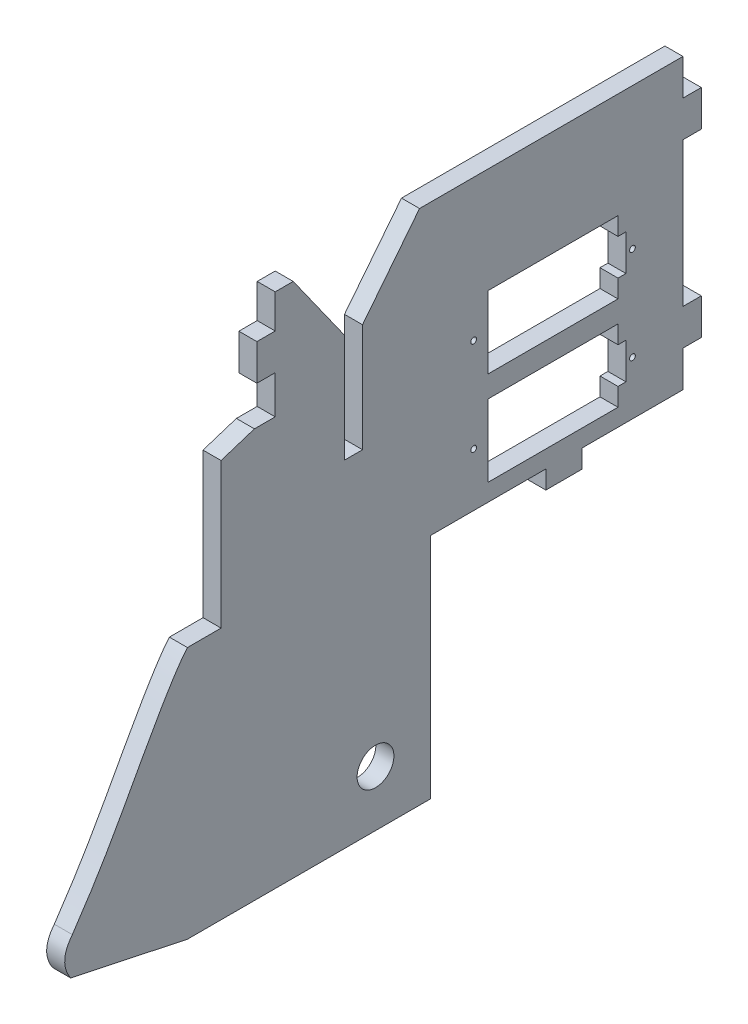
from build123d import *

# Parameters (mm, degrees)
SKETCH1_W                = 71.755
SKETCH1_H                = 50.8
MAIN_BODY_DEPTH          = 3.175
SKETCH2_W                = 3.2258
SKETCH2_H                = 6.35
SKETCH2_W_2              = 6.35
SKETCH2_H_2              = 3.2258
TABS_DEPTH               = 3.175
NOSE_SECTION_DEPTH       = 3.175
SKETCH8_R                = 0.508
CUT_FOR_MOTORS_DEPTH     = 4.1750001
SLOT_FOR_FIREWALL_DEPTH  = 4.1750001
EXTENSION_FOR_AXLE_DEPTH = 3.175
SKETCH11_R               = 3.2385
CUT_FOR_AXLE_DEPTH       = 4.1750001


with BuildPart() as part:
    # Sketch1 → main body (new body)
    with BuildSketch(Plane(origin=(0, 0, 0), x_dir=(0, 0, -1), z_dir=(1, 0, 0))):
        Rectangle(SKETCH1_W, SKETCH1_H)
    extrude(amount=MAIN_BODY_DEPTH)

    # Sketch2 → tabs (add)
    with BuildSketch(Plane(origin=(3.175, 0, 0), x_dir=(0, 0, -1), z_dir=(1, 0, 0))):
        with Locations((-37.4904, 16.256)):
            Rectangle(SKETCH2_W, SKETCH2_H)
        with Locations((37.4904, 15.875)):
            Rectangle(SKETCH2_W, SKETCH2_H)
        with Locations((37.4904, -15.875)):
            Rectangle(SKETCH2_W, SKETCH2_H)
        with Locations((14.9225, -27.0129)):
            Rectangle(SKETCH2_W_2, SKETCH2_H_2)
    extrude(amount=-TABS_DEPTH)

    # Sketch3 → nose section (add)
    with BuildSketch(Plane.ZY):
        with BuildLine():
            Line((51.326941337, -21.081213956), (45.4025, -21.081213956))
            Line((45.4025, -21.081213956), (45.4025, 4.459215194))
            Line((45.4025, 4.459215194), (39.534554548, 6.35))
            Line((39.534554548, 6.35), (35.8775, 6.35))
            Line((35.8775, 6.35), (35.8775, -25.4))
            Line((35.8775, -25.4), (35.8775, -57.323174337))
            Line((35.8775, -57.323174337), (42.8625, -65.53778801))
            Line((42.8625, -65.53778801), (51.326941337, -65.53778801))
            Line((51.326941337, -65.53778801), (71.872461292, -61.17070293))
            add(Edge.make_bspline(
                [(71.573902629, -54.710271069), (74.102249919, -57.868358167), (71.872461292, -61.17070293)],
                knots=[0, 0, 0, 1, 1, 1], degree=2))
            add(Edge.make_bspline(
                [(71.573902629, -54.710271069), (65.707060229, -46.091929926), (62.410515677, -39.350220463), (53.353361757, -23.389519751), (51.326941337, -21.081213956)],
                knots=[0, 0, 0, 0, 0.673726306, 1, 1, 1, 1], degree=3))
        make_face()
    extrude(amount=-NOSE_SECTION_DEPTH)

    # Sketch8 → cut for motors (cut, through all)
    with BuildSketch(Plane.ZY):
        with Locations((-26.9875, 0.508)):
            Circle(SKETCH8_R)
        with Locations((0.9525, 0.508)):
            Circle(SKETCH8_R)
        with Locations((-26.9875, -16.002)):
            Circle(SKETCH8_R)
        with Locations((0.9525, -16.002)):
            Circle(SKETCH8_R)
        Polygon((-1.5875, -5.842), (-1.5875, 6.858), (-24.4475, 6.858), (-24.4475, 3.683), (-25.8445, 3.683), (-25.8445, -2.667), (-24.4475, -2.667), (-24.4475, -5.842), align=None)
        Polygon((-1.5875, -22.352), (-1.5875, -9.652), (-24.4475, -9.652), (-24.4475, -12.827), (-25.8445, -12.827), (-25.8445, -19.177), (-24.4475, -19.177), (-24.4475, -22.352), align=None)
    extrude(amount=-CUT_FOR_MOTORS_DEPTH, mode=Mode.SUBTRACT)

    # Sketch9 → slot for firewall (cut, through all)
    with BuildSketch(Plane.ZY):
        Polygon((20.5105, -6.34593574), (23.6855, -6.34593574), (23.6855, 12.7), (32.7025, 25.4), (23.1775, 25.4), (20.0025, 25.4), (10.4775, 25.4), (20.5105, 12.70406426), align=None)
    extrude(amount=-SLOT_FOR_FIREWALL_DEPTH, mode=Mode.SUBTRACT)

    # Sketch10 → extension for axle (add)
    with BuildSketch(Plane.ZY):
        Polygon((35.8775, -57.323174337), (35.8775, -25.4), (8.5725, -25.4), (8.5725, -65.53778801), (42.8625, -65.53778801), align=None)
    extrude(amount=-EXTENSION_FOR_AXLE_DEPTH)

    # Sketch11 → cut for axle (cut, through all)
    with BuildSketch(Plane.ZY):
        with Locations((18.2245, -55.753)):
            Circle(SKETCH11_R)
    extrude(amount=-CUT_FOR_AXLE_DEPTH, mode=Mode.SUBTRACT)


solid = part.part
